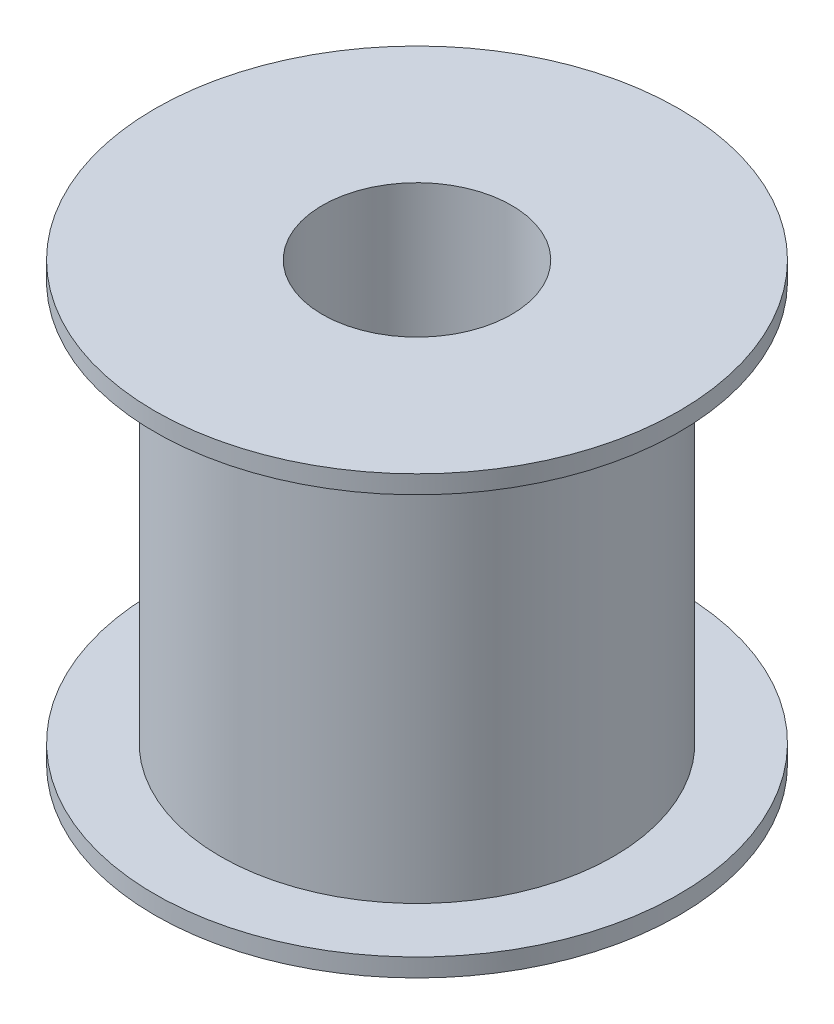
from build123d import *

# Parameters (mm, degrees)
SKETCH1_R           = 36
SKETCH1_R_2         = 13
BOSS_EXTRUDE1_DEPTH = 60
SKETCH2_W           = 9
SKETCH2_H           = 55


with BuildPart() as part:
    # Sketch1 → Boss-Extrude1 (new body)
    with BuildSketch(Plane(origin=(0, 0, 0), x_dir=(1, 0, 0), z_dir=(0, 1, 0))):
        Circle(SKETCH1_R)
        Circle(SKETCH1_R_2, mode=Mode.SUBTRACT)
    extrude(amount=BOSS_EXTRUDE1_DEPTH)

    # Sketch2 → Cut-Revolve1 (revolve, cut)
    with BuildSketch(Plane.XY):
        with Locations((-31.5, 30)):
            Rectangle(SKETCH2_W, SKETCH2_H)
    revolve(axis=Axis((0, 0, 0), (0, 1, 0)), mode=Mode.SUBTRACT)


solid = part.part
